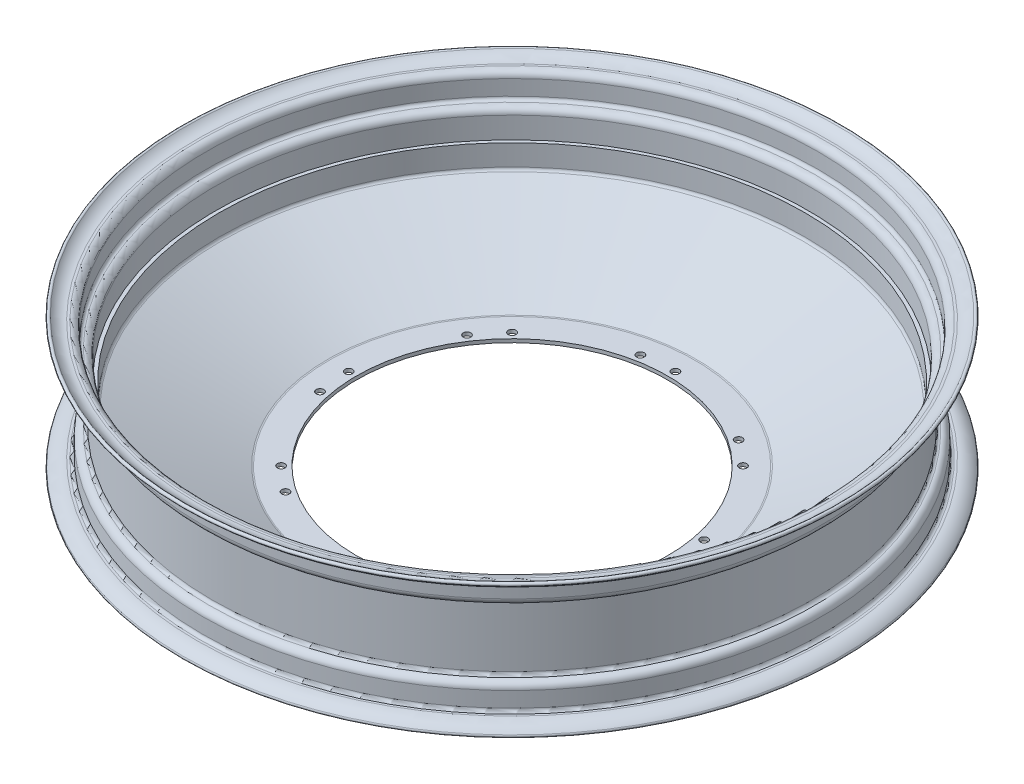
from build123d import *

# Parameters (mm, degrees)
SKETCH4_R               = 2.5
CUT_EXTRUDE3_DEPTH      = 41.899911875
CUT_EXTRUDE3_DEPTH_BACK = 48.292520738


with BuildPart() as part:
    # Sketch3 → Revolve2 (revolve)
    with BuildSketch(Plane.XY):
        with BuildLine():
            Line((-206.357184443, 37.167999668), (-204.858623911, 37.167999539))
            ThreePointArc((-204.858623911, 37.167999539), (-201.829260112, 35.912281795), (-200.576663362, 32.88162618))
            Line((-200.576663362, 32.88162618), (-200.586978109, 22.866743837))
            ThreePointArc((-200.586978109, 22.866743837), (-200.001921833, 21.451197849), (-198.58697917, 20.864682527))
            ThreePointArc((-198.58697917, 20.864682527), (-195.556319434, 19.609342395), (-194.30097917, 16.578682988))
            Line((-194.30097917, 16.578682988), (-194.30097917, 2.528130596))
            Line((-194.30097917, 2.528130596), (-192.01497917, 2.528130596))
            Line((-192.01497917, 2.528130596), (-192.01497917, -11.253759734))
            ThreePointArc((-192.01497917, -11.253759734), (-191.695573625, -12.338011679), (-190.839376891, -13.075947539))
            Line((-190.839376891, -13.075947539), (-120.654241398, -44.82924188))
            ThreePointArc((-120.654241398, -44.82924188), (-120.252729669, -44.961697151), (-119.83231687, -45.006520638))
            Line((-119.83231687, -45.006520638), (-102.000000909, -45.005569111))
            Line((-102.000000909, -45.005569111), (-102.000000909, -47.292520638))
            Line((-102.000000909, -47.292520638), (-119.83231687, -47.292520638))
            ThreePointArc((-119.83231687, -47.292520638), (-120.734707432, -47.196309743), (-121.596527992, -46.912002542))
            Line((-121.596527992, -46.912002542), (-191.476581449, -15.296734004))
            ThreePointArc((-191.476581449, -15.296734004), (-193.385231115, -15.438327355), (-194.30097917, -17.118921809))
            Line((-194.30097917, -17.118921809), (-194.30097917, -22.812781056))
            ThreePointArc((-194.30097917, -22.812781056), (-195.556319434, -25.843440462), (-198.58697917, -27.098780594))
            ThreePointArc((-198.58697917, -27.098780594), (-200.001921833, -27.685295917), (-200.586978109, -29.100841904))
            Line((-200.586978109, -29.100841904), (-200.576663362, -39.115724247))
            ThreePointArc((-200.576663362, -39.115724247), (-201.829260112, -42.146379863), (-204.858623911, -43.402097607))
            Line((-204.858623911, -43.402097607), (-206.357184443, -43.402097735))
            ThreePointArc((-206.357184443, -43.402097735), (-210.497321297, -44.278803929), (-213.926731129, -46.758419852))
            ThreePointArc((-213.926731129, -46.758419852), (-215.541213082, -46.838081786), (-215.620875016, -45.223599833))
            ThreePointArc((-215.620875016, -45.223599833), (-211.423927408, -42.189019941), (-206.35718464, -41.116097735))
            Line((-206.35718464, -41.116097735), (-204.858624108, -41.116097607))
            ThreePointArc((-204.858624108, -41.116097607), (-203.446538492, -40.530766467), (-202.86266215, -39.118078693))
            Line((-202.86266215, -39.118078693), (-202.872976897, -29.10319635))
            ThreePointArc((-202.872976897, -29.10319635), (-201.619199369, -26.069683029), (-198.58697917, -24.812781355))
            ThreePointArc((-198.58697917, -24.812781355), (-197.172036507, -24.226266033), (-196.586980231, -22.810720046))
            Line((-196.586980231, -22.810720046), (-196.586980231, 16.576621979))
            ThreePointArc((-196.586980231, 16.576621979), (-197.172036507, 17.992167966), (-198.58697917, 18.578683288))
            ThreePointArc((-198.58697917, 18.578683288), (-201.619199133, 19.835585393), (-202.872976897, 22.869098283))
            Line((-202.872976897, 22.869098283), (-202.86266215, 32.883980626))
            ThreePointArc((-202.86266215, 32.883980626), (-203.446538492, 34.2966684), (-204.858624108, 34.881999539))
            Line((-204.858624108, 34.881999539), (-206.35718464, 34.881999668))
            ThreePointArc((-206.35718464, 34.881999668), (-211.423927408, 35.954921874), (-215.620875016, 38.989501766))
            ThreePointArc((-215.620875016, 38.989501766), (-215.541213082, 40.603983719), (-213.926731129, 40.524321785))
            ThreePointArc((-213.926731129, 40.524321785), (-210.497321297, 38.044705862), (-206.357184443, 37.167999668))
        make_face()
    revolve(axis=Axis((0, 240.888952165, 0), (0, -1, 0)))

    # Sketch4 → Cut-Extrude3 (cut, two sides)
    with BuildSketch(Plane(origin=(0, 0, 0), x_dir=(1, 0, 0), z_dir=(0, 1, 0))) as cut_extrude3_sk:
        with Locations((0, 107)):
            Circle(SKETCH4_R)
        with Locations((-3884.181572475, -9484.24383099)):
            Circle(SKETCH4_R)
        with Locations((-13412.746254639, -13519.746254639)):
            Circle(SKETCH4_R)
        with Locations((-23003.990085629, -9635.564682164)):
            Circle(SKETCH4_R)
        with Locations((-27039.492509279, -107)):
            Circle(SKETCH4_R)
        with Locations((-23155.310936803, 9484.24383099)):
            Circle(SKETCH4_R)
        with Locations((-13626.746254639, 13519.746254639)):
            Circle(SKETCH4_R)
        with Locations((-4035.502423649, 9635.564682164)):
            Circle(SKETCH4_R)
        with Locations((-20.874664456, 104.944025003)):
            Circle(SKETCH4_R)
        with Locations((-3900.395983129, -9470.93700806)):
            Circle(SKETCH4_R)
        with Locations((-13414.802229636, -13498.871590184)):
            Circle(SKETCH4_R)
        with Locations((-22990.6832627, -9619.35027151)):
            Circle(SKETCH4_R)
        with Locations((-27018.617844823, -104.944025003)):
            Circle(SKETCH4_R)
        with Locations((-23139.096526149, 9470.93700806)):
            Circle(SKETCH4_R)
        with Locations((-13624.690279642, 13498.871590184)):
            Circle(SKETCH4_R)
        with Locations((-4048.809246579, 9619.35027151)):
            Circle(SKETCH4_R)
        with Locations((75.660425587, 75.660425587)):
            Circle(SKETCH4_R)
        with Locations((59.446014933, 88.967248516)):
            Circle(SKETCH4_R)
        with Locations((107, 0)):
            Circle(SKETCH4_R)
        with Locations((104.944025003, 20.874664456)):
            Circle(SKETCH4_R)
        with Locations((75.660425587, -75.660425587)):
            Circle(SKETCH4_R)
        with Locations((88.967248516, -59.446014933)):
            Circle(SKETCH4_R)
        with Locations((0, -107)):
            Circle(SKETCH4_R)
        with Locations((20.874664456, -104.944025003)):
            Circle(SKETCH4_R)
        with Locations((-75.660425587, -75.660425587)):
            Circle(SKETCH4_R)
        with Locations((-59.446014933, -88.967248516)):
            Circle(SKETCH4_R)
        with Locations((-107, 0)):
            Circle(SKETCH4_R)
        with Locations((-104.944025003, -20.874664456)):
            Circle(SKETCH4_R)
        with Locations((-75.660425587, 75.660425587)):
            Circle(SKETCH4_R)
        with Locations((-88.967248516, 59.446014933)):
            Circle(SKETCH4_R)
    extrude(amount=CUT_EXTRUDE3_DEPTH, mode=Mode.SUBTRACT)
    extrude(cut_extrude3_sk.sketch, amount=-CUT_EXTRUDE3_DEPTH_BACK, mode=Mode.SUBTRACT)


solid = part.part
